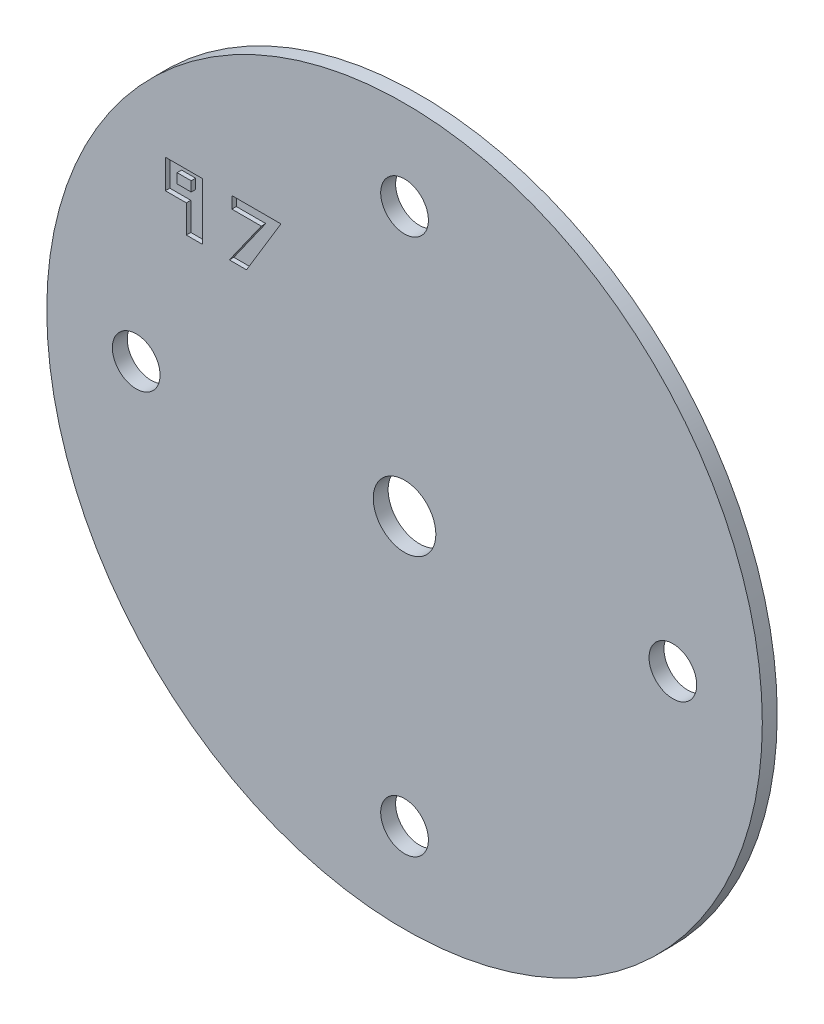
from build123d import *

# Parameters (mm, degrees)
SKETCH1_R           = 24
BOSS_EXTRUDE1_DEPTH = 1
SKETCH3_R           = 2.1
CUT_EXTRUDE2_DEPTH  = 2
SKETCH2_R           = 1.6
CUT_EXTRUDE3_DEPTH  = 2
SKETCH4_W           = 0.94378815
SKETCH4_H           = 0.65487341
CUT_EXTRUDE4_DEPTH  = 0.3


with BuildPart() as part:
    # Sketch1 → Boss-Extrude1 (new body)
    with BuildSketch(Plane.XY):
        Circle(SKETCH1_R)
    extrude(amount=BOSS_EXTRUDE1_DEPTH)

    # Sketch3 → Cut-Extrude2 (cut)
    with BuildSketch(Plane.XY.offset(1)):
        Circle(SKETCH3_R)
    extrude(amount=-CUT_EXTRUDE2_DEPTH, mode=Mode.SUBTRACT)

    # Sketch2 → Cut-Extrude3 (cut, through all)
    with BuildSketch(Plane.XY.offset(1)):
        with Locations((-18, 0)):
            Circle(SKETCH2_R)
        with Locations((0, 18)):
            Circle(SKETCH2_R)
        with Locations((18, 0)):
            Circle(SKETCH2_R)
        with Locations((0, -18)):
            Circle(SKETCH2_R)
    extrude(amount=-CUT_EXTRUDE3_DEPTH, mode=Mode.SUBTRACT)

    # Sketch4 → Cut-Extrude4 (cut)
    with BuildSketch(Plane.XY.offset(1)):
        Polygon((-11.58574855, 12.841946562), (-8.291473373, 12.841946562), (-10.597161191, 9.019905494), (-11.751924249, 9.019905494), (-9.607705981, 12.052611994), (-11.58574855, 12.052611994), align=None)
        Polygon((-13.559084971, 12.841946562), (-16.044695483, 12.841946562), (-16.044695483, 10.889382104), (-14.639227012, 10.889382104), (-14.639227012, 9.019905494), (-13.559084971, 9.019905494), align=None)
        with Locations((-14.783101119, 12.008686539)):
            Rectangle(SKETCH4_W, SKETCH4_H, mode=Mode.SUBTRACT)
    extrude(amount=-CUT_EXTRUDE4_DEPTH, mode=Mode.SUBTRACT)


solid = part.part
